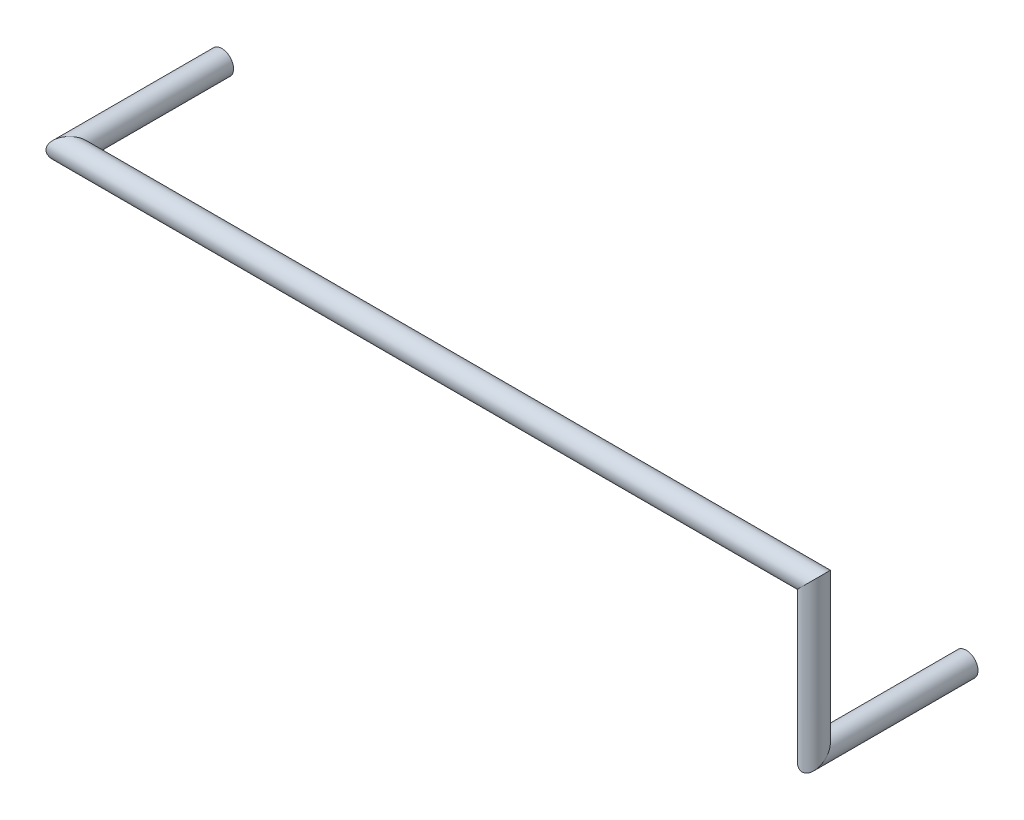
from build123d import *

# Parameters (mm, degrees)
SWEEP1_PROFILE_R = 0.2


with BuildPart() as part:
    # Sweep1: sweep along a curve in space
    with BuildLine() as sweep1_path:
        Line((0, 0, 0), (0, 0, 2.6))
        Line((0, 0, 2.6), (0, 2.54, 2.6))
        Line((0, 2.54, 2.6), (-12.7, 2.54, 2.6))
        Line((-12.7, 2.54, 2.6), (-12.7, 2.54, 0))
    # Sweep1 profile (on start of the path) → Sweep1 (sweep)
    with BuildSketch(Plane.XY):
        Circle(SWEEP1_PROFILE_R)
    sweep(path=sweep1_path.line, transition=Transition.RIGHT)


solid = part.part
